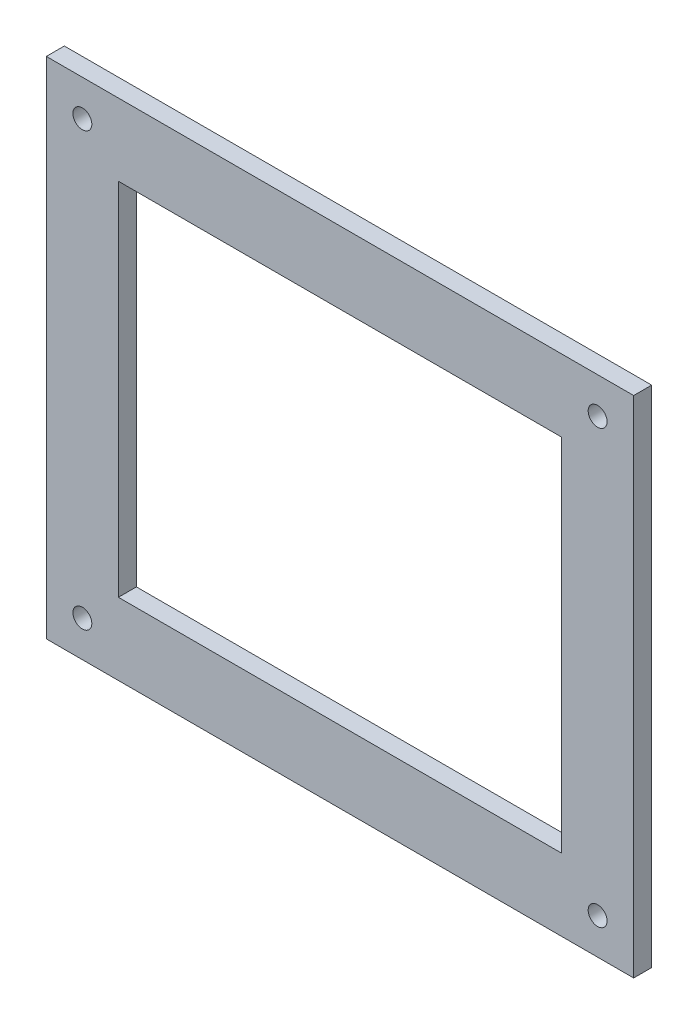
from build123d import *

# Parameters (mm, degrees)
SKETCH1_W           = 326
SKETCH1_H           = 280
SKETCH1_R           = 5.25
SKETCH1_W_2         = 246
SKETCH1_H_2         = 200
BOSS_EXTRUDE1_DEPTH = 10


with BuildPart() as part:
    # Sketch1 → Boss-Extrude1 (new body)
    with BuildSketch(Plane.XY):
        with Locations((123, 100)):
            Rectangle(SKETCH1_W, SKETCH1_H)
        with Locations((-20, 220)):
            Circle(SKETCH1_R, mode=Mode.SUBTRACT)
        with Locations((266, 220)):
            Circle(SKETCH1_R, mode=Mode.SUBTRACT)
        with Locations((266, -20)):
            Circle(SKETCH1_R, mode=Mode.SUBTRACT)
        with Locations((-20, -20)):
            Circle(SKETCH1_R, mode=Mode.SUBTRACT)
        with Locations((123, 100)):
            Rectangle(SKETCH1_W_2, SKETCH1_H_2, mode=Mode.SUBTRACT)
    extrude(amount=BOSS_EXTRUDE1_DEPTH)


solid = part.part
